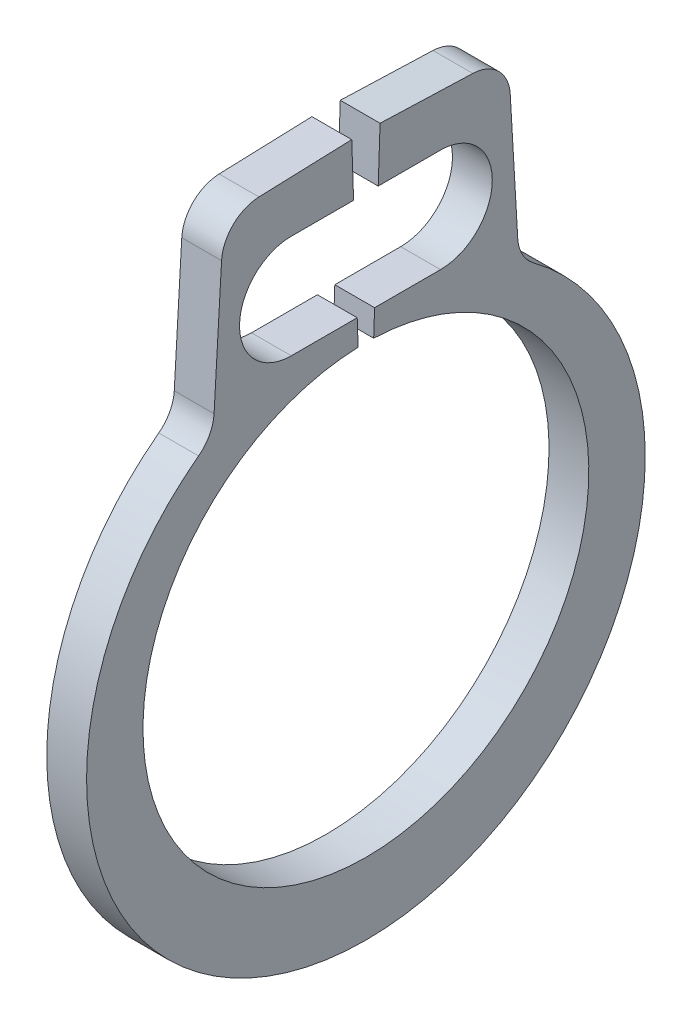
from build123d import *

# Parameters (mm, degrees)
BOSS_EXTRUDE1_DEPTH      = 0.127
BOSS_EXTRUDE1_DEPTH_BACK = 0.127
FILLET1_R                = 0.24765


with BuildPart() as part:
    # Sketch3 → Boss-Extrude1 (new body, two sides)
    with BuildSketch(Plane(origin=(0, 0, 0), x_dir=(0, 0, -1), z_dir=(1, 0, 0))) as boss_extrude1_sk:
        with BuildLine():
            Line((-0.907799386, 2.560678154), (-0.975790746, 1.394258103))
            ThreePointArc((-0.975790746, 1.394258103), (0, -1.8796), (0.975790746, 1.394258103))
            Line((0.975790746, 1.394258103), (0.907799386, 2.560678154))
            Line((0.907799386, 2.560678154), (0.090417616, 2.589221755))
            Line((0.090417616, 2.589221755), (0.078498398, 2.2479))
            Line((0.078498398, 2.2479), (0.476156827, 2.2479))
            ThreePointArc((0.476156827, 2.2479), (0.806356827, 1.9177), (0.476156827, 1.5875))
            Line((0.476156827, 1.5875), (0.055436722, 1.5875))
            Line((0.055436722, 1.5875), (0.049641044, 1.421533512))
            ThreePointArc((0.049641044, 1.421533512), (0, -1.4224), (-0.049641044, 1.421533512))
            Line((-0.049641044, 1.421533512), (-0.055436722, 1.5875))
            Line((-0.055436722, 1.5875), (-0.476156827, 1.5875))
            ThreePointArc((-0.476156827, 1.5875), (-0.806356827, 1.9177), (-0.476156827, 2.2479))
            Line((-0.476156827, 2.2479), (-0.078498398, 2.2479))
            Line((-0.078498398, 2.2479), (-0.090417616, 2.589221755))
            Line((-0.090417616, 2.589221755), (-0.907799386, 2.560678154))
        make_face()
    extrude(amount=BOSS_EXTRUDE1_DEPTH)
    extrude(boss_extrude1_sk.sketch, amount=-BOSS_EXTRUDE1_DEPTH_BACK)

    # Fillet1
    fillet1_edges = [part.edges().sort_by_distance(p)[0] for p in [
        (0, 1.394258103, 0.975790746),
        (0, 2.560678154, 0.907799386),
        (0, 2.560678154, -0.907799386),
        (0, 1.394258103, -0.975790746),
    ]]
    fillet(fillet1_edges, radius=FILLET1_R)


solid = part.part
